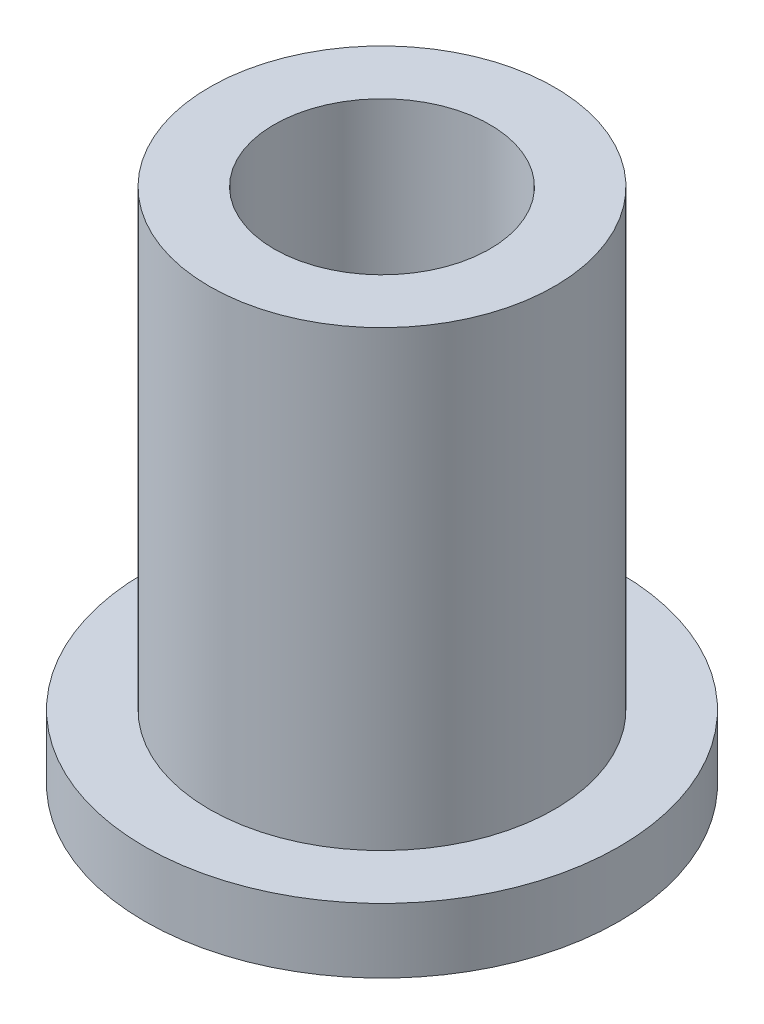
from build123d import *

# Parameters (mm, degrees)
SKETCH2_R           = 4
SKETCH2_R_2         = 2.5
BOSS_EXTRUDE1_DEPTH = 12
SKETCH3_R           = 5.5
SKETCH3_R_2         = 4
BOSS_EXTRUDE2_DEPTH = 1.5


with BuildPart() as part:
    # Sketch2 → Boss-Extrude1 (new body)
    with BuildSketch(Plane(origin=(0, 0, 0), x_dir=(1, 0, 0), z_dir=(0, 1, 0))):
        Circle(SKETCH2_R)
        Circle(SKETCH2_R_2, mode=Mode.SUBTRACT)
    extrude(amount=BOSS_EXTRUDE1_DEPTH)

    # Sketch3 → Boss-Extrude2 (add)
    with BuildSketch(Plane(origin=(0, 0, 0), x_dir=(1, 0, 0), z_dir=(0, 1, 0))):
        Circle(SKETCH3_R)
        Circle(SKETCH3_R_2, mode=Mode.SUBTRACT)
    extrude(amount=BOSS_EXTRUDE2_DEPTH)


solid = part.part
